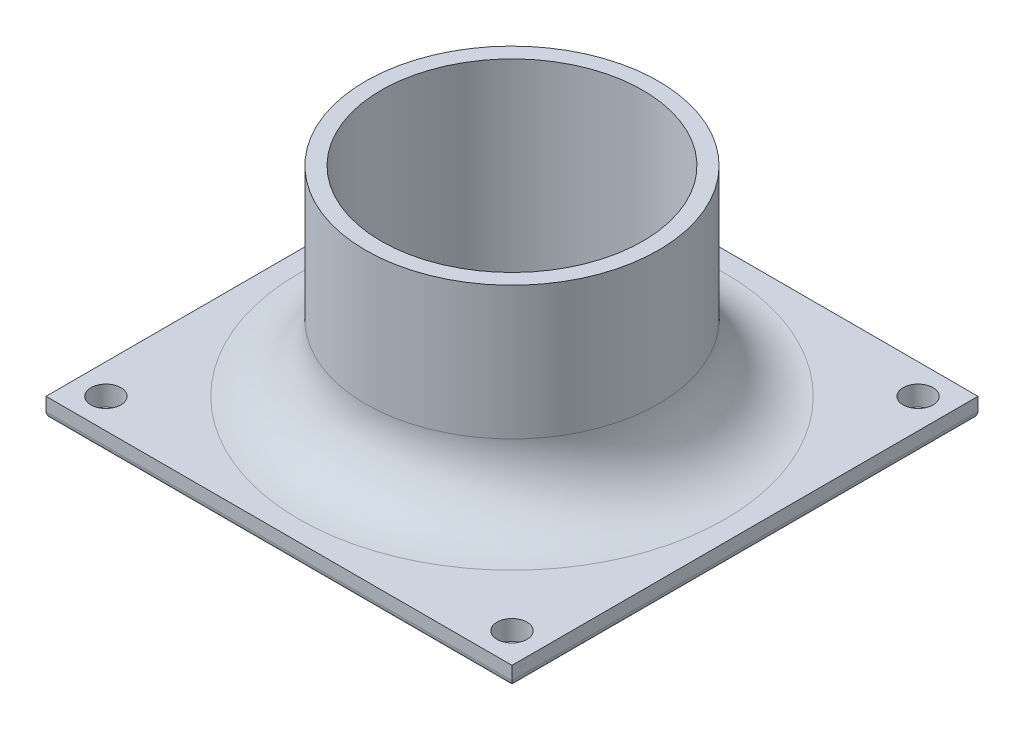
from build123d import *

# Parameters (mm, degrees)
SKETCH1_W                                  = 70
SKETCH1_H                                  = 70
BOSS_EXTRUDE1_DEPTH                        = 3
SKETCH2_R                                  = 18
CUT_EXTRUDE1_DEPTH                         = 3
SKETCH3_R                                  = 22
SKETCH3_R_2                                = 19.65
BOSS_EXTRUDE2_DEPTH                        = 30
FILLET1_R                                  = 10
SKETCH4_R                                  = 2.25
CUT_EXTRUDE2_DEPTH                         = 3
MIRROR1_AT_THE_SECOND_PLANE_COPY_1_SKETC_R = 2.25
MIRROR1_AT_THE_SECOND_PLANE_COPY_1_DEPTH   = 3
FILLET4_R                                  = 1


with BuildPart() as part:
    # Sketch1 → Boss-Extrude1 (new body)
    with BuildSketch(Plane(origin=(0, 0, 0), x_dir=(1, 0, 0), z_dir=(0, 1, 0))):
        Rectangle(SKETCH1_W, SKETCH1_H)
    extrude(amount=BOSS_EXTRUDE1_DEPTH)

    # Sketch2 → Cut-Extrude1 (cut)
    with BuildSketch(Plane(origin=(0, 3, 0), x_dir=(1, 0, 0), z_dir=(0, 1, 0))):
        Circle(SKETCH2_R)
    extrude(amount=-CUT_EXTRUDE1_DEPTH, mode=Mode.SUBTRACT)

    # Sketch3 → Boss-Extrude2 (add)
    with BuildSketch(Plane(origin=(0, 3, 0), x_dir=(1, 0, 0), z_dir=(0, 1, 0))):
        Circle(SKETCH3_R)
        Circle(SKETCH3_R_2, mode=Mode.SUBTRACT)
    extrude(amount=BOSS_EXTRUDE2_DEPTH)

    # Fillet1
    fillet1_edges = [part.edges().sort_by_distance(p)[0] for p in [
        (-22, 3, 0),
    ]]
    fillet(fillet1_edges, radius=FILLET1_R)

    # Sketch4 → Cut-Extrude2 (cut)
    with BuildSketch(Plane(origin=(0, 0, 0), x_dir=(-1, 0, 0), z_dir=(0, -1, 0))):
        with Locations((30.5, -30.5)):
            Circle(SKETCH4_R)
    cut_extrude2 = extrude(amount=-CUT_EXTRUDE2_DEPTH, mode=Mode.SUBTRACT)

    # Mirror1: Cut-Extrude2 across plane
    add(cut_extrude2.mirror(Plane(origin=(0, 0, 0), x_dir=(0, 0, 1), z_dir=(1, 0, 0))), mode=Mode.SUBTRACT)

    # Mirror1 at the second plane: Cut-Extrude2 across plane
    add(cut_extrude2.mirror(Plane.XY), mode=Mode.SUBTRACT)

    # Mirror1 at the second plane copy 1 sketc → Mirror1 at the second plane copy 1 (cut)
    with BuildSketch(Plane.XZ):
        with Locations((30.5, -30.5)):
            Circle(MIRROR1_AT_THE_SECOND_PLANE_COPY_1_SKETC_R)
    extrude(amount=-MIRROR1_AT_THE_SECOND_PLANE_COPY_1_DEPTH, mode=Mode.SUBTRACT)

    # Fillet4
    fillet4_edges = [part.edges().sort_by_distance(p)[0] for p in [
        (0, 0, 35),
        (-35, 0, 0),
        (0, 0, -35),
        (35, 0, 0),
    ]]
    fillet(fillet4_edges, radius=FILLET4_R)


solid = part.part
